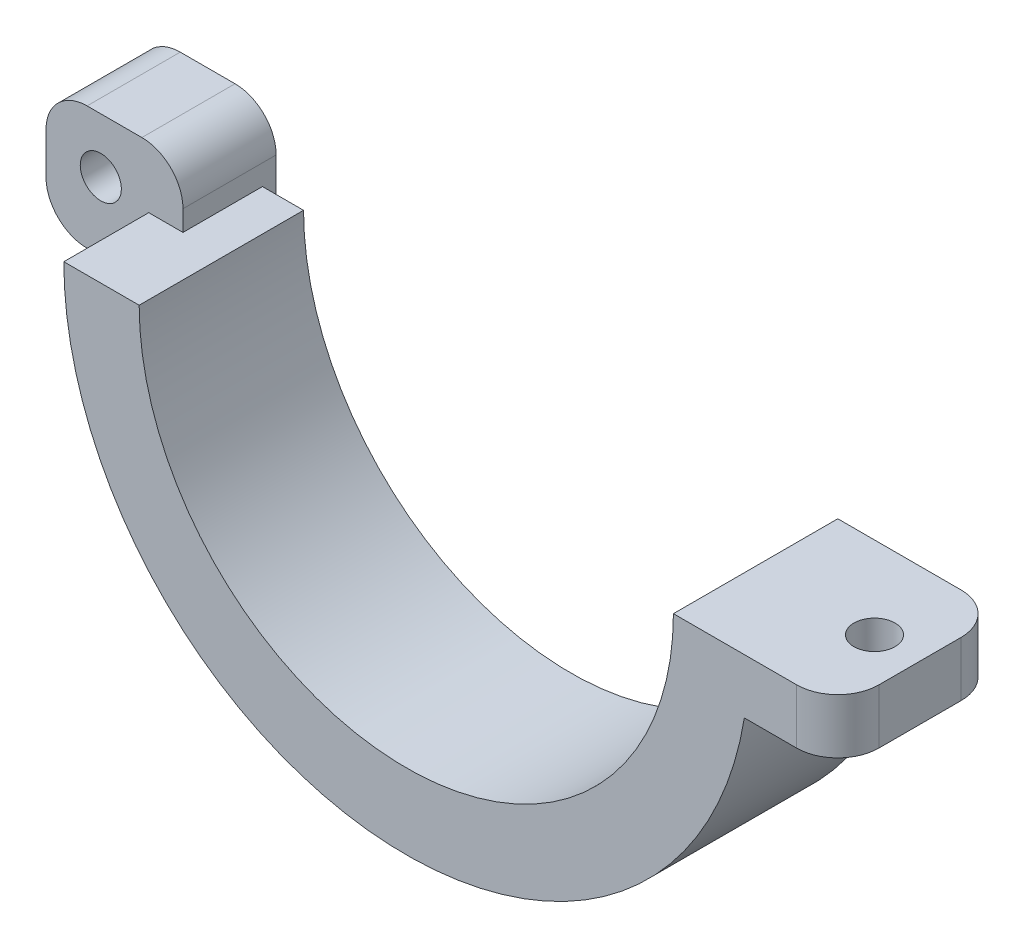
from build123d import *

# Parameters (mm, degrees)
BOSS_EXTRUDE8_DEPTH       = 12
SKETCH4_W                 = 8
SKETCH4_H                 = 4
BOSS_EXTRUDE10_DEPTH      = 12
SKETCH5_R                 = 1.5
CUT_EXTRUDE2_DEPTH        = 12
SKETCH6_W                 = 10
SKETCH6_H                 = 9
BOSS_EXTRUDE11_DEPTH      = 1
BOSS_EXTRUDE11_DEPTH_BACK = 5.8
SKETCH7_R                 = 1.5
CUT_EXTRUDE3_DEPTH        = 10
FILLET1_R                 = 3
FILLET3_R                 = 3
FILLET4_R                 = 3
FILLET5_R                 = 3
FILLET6_R                 = 3


with BuildPart() as part:
    # Sketch1 → Boss-Extrude8 (new body)
    with BuildSketch(Plane.XY):
        with BuildLine():
            Line((25, 0), (19.5, 0))
            ThreePointArc((19.5, 0), (0, -19.5), (-19.5, 0))
            Line((-19.5, 0), (-25, 0))
            ThreePointArc((-25, 0), (0, -25), (25, 0))
        make_face()
    extrude(amount=BOSS_EXTRUDE8_DEPTH)

    # Sketch4 → Boss-Extrude10 (add)
    with BuildSketch(Plane(origin=(0, 0, 0), x_dir=(-1, 0, 0), z_dir=(0, 0, -1))):
        with Locations((-27.5, -2)):
            Rectangle(SKETCH4_W, SKETCH4_H)
    extrude(amount=-BOSS_EXTRUDE10_DEPTH)

    # Sketch5 → Cut-Extrude2 (cut)
    with BuildSketch(Plane.XZ.offset(4)):
        with Locations((28.177925359, 6)):
            Circle(SKETCH5_R)
    extrude(amount=-CUT_EXTRUDE2_DEPTH, mode=Mode.SUBTRACT)

    # Sketch6 → Boss-Extrude11 (add, two sides)
    with BuildSketch(Plane(origin=(0, 0, 0), x_dir=(-1, 0, 0), z_dir=(0, 0, -1))) as boss_extrude11_sk:
        with Locations((27.5, 0)):
            Rectangle(SKETCH6_W, SKETCH6_H)
    extrude(amount=BOSS_EXTRUDE11_DEPTH)
    extrude(boss_extrude11_sk.sketch, amount=-BOSS_EXTRUDE11_DEPTH_BACK)

    # Sketch7 → Cut-Extrude3 (cut)
    with BuildSketch(Plane(origin=(0, 0, -1), x_dir=(-1, 0, 0), z_dir=(0, 0, -1))):
        with Locations((28.5, 0.5)):
            Circle(SKETCH7_R)
    extrude(amount=-CUT_EXTRUDE3_DEPTH, mode=Mode.SUBTRACT)

    # Fillet1
    fillet1_edges = [part.edges().sort_by_distance(p)[0] for p in [
        (-32.5, -4.5, 2.4),
    ]]
    fillet(fillet1_edges, radius=FILLET1_R)

    # Fillet3
    fillet3_edges = [part.edges().sort_by_distance(p)[0] for p in [
        (-32.5, 4.5, 2.4),
    ]]
    fillet(fillet3_edges, radius=FILLET3_R)

    # Fillet4
    fillet4_edges = [part.edges().sort_by_distance(p)[0] for p in [
        (-22.5, 4.5, 2.4),
    ]]
    fillet(fillet4_edges, radius=FILLET4_R)

    # Fillet5
    fillet5_edges = [part.edges().sort_by_distance(p)[0] for p in [
        (31.5, -2, 0),
    ]]
    fillet(fillet5_edges, radius=FILLET5_R)

    # Fillet6
    fillet6_edges = [part.edges().sort_by_distance(p)[0] for p in [
        (31.5, -2, 12),
    ]]
    fillet(fillet6_edges, radius=FILLET6_R)


solid = part.part
